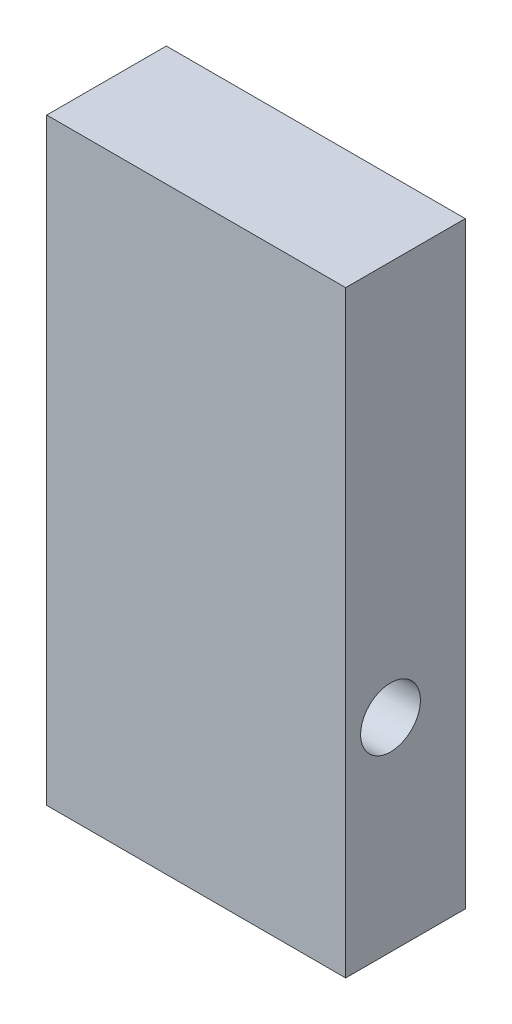
from build123d import *

# Parameters (mm, degrees)
SKETCH1_W           = 50
SKETCH1_H           = 100
BOSS_EXTRUDE1_DEPTH = 20
SKETCH3_R           = 5
CUT_EXTRUDE2_DEPTH  = 130


with BuildPart() as part:
    # Sketch1 → Boss-Extrude1 (new body)
    with BuildSketch(Plane.XY):
        Rectangle(SKETCH1_W, SKETCH1_H)
    extrude(amount=BOSS_EXTRUDE1_DEPTH)

    # Sketch3 → Cut-Extrude2 (cut)
    with BuildSketch(Plane.ZY.offset(25)):
        with Locations((12.5, -16)):
            Circle(SKETCH3_R)
    extrude(amount=-CUT_EXTRUDE2_DEPTH, mode=Mode.SUBTRACT)


solid = part.part
